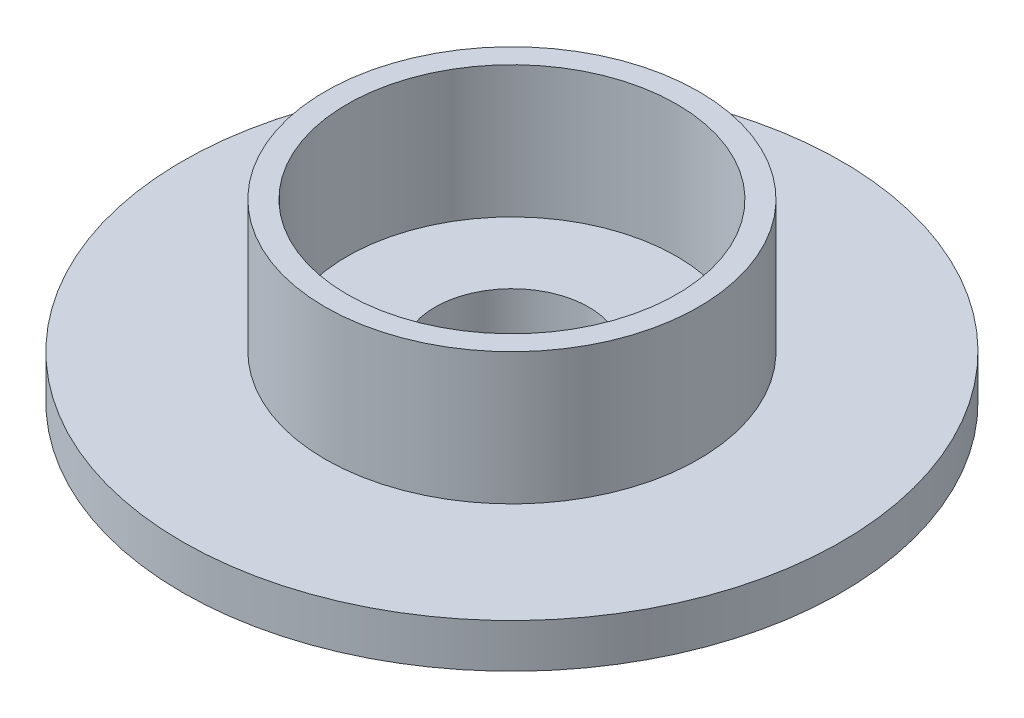
from build123d import *

# Parameters (mm, degrees)
SKETCH1_R           = 75
BOSS_EXTRUDE1_DEPTH = 10
SKETCH2_R           = 42.5
SKETCH2_R_2         = 37.5
BOSS_EXTRUDE2_DEPTH = 30
SKETCH4_R           = 17.5
CUT_EXTRUDE2_DEPTH  = 11


with BuildPart() as part:
    # Sketch1 → Boss-Extrude1 (new body)
    with BuildSketch(Plane(origin=(0, 0, 0), x_dir=(1, 0, 0), z_dir=(0, 1, 0))):
        with Locations(Location((-26.550234212, 13.507577144, 0), (0, 0, 270))):  # turned: the seam where the file's is
            Circle(SKETCH1_R)
    extrude(amount=BOSS_EXTRUDE1_DEPTH)

    # Sketch2 → Boss-Extrude2 (add)
    with BuildSketch(Plane(origin=(0, 10, 0), x_dir=(1, 0, 0), z_dir=(0, 1, 0))):
        with Locations(Location((-26.550234212, 13.507577144, 0), (0, 0, 270))):  # turned: the seam where the file's is
            Circle(SKETCH2_R)
        with Locations(Location((-26.550234212, 13.507577144, 0), (0, 0, 270))):  # turned: the seam where the file's is
            Circle(SKETCH2_R_2, mode=Mode.SUBTRACT)
    extrude(amount=BOSS_EXTRUDE2_DEPTH)

    # Sketch4 → Cut-Extrude2 (cut, through all)
    with BuildSketch(Plane(origin=(0, 10, 0), x_dir=(1, 0, 0), z_dir=(0, 1, 0))):
        with Locations(Location((-26.550234212, 13.507577144, 0), (0, 0, 270))):  # turned: the seam where the file's is
            Circle(SKETCH4_R)
    extrude(amount=-CUT_EXTRUDE2_DEPTH, mode=Mode.SUBTRACT)


solid = part.part
